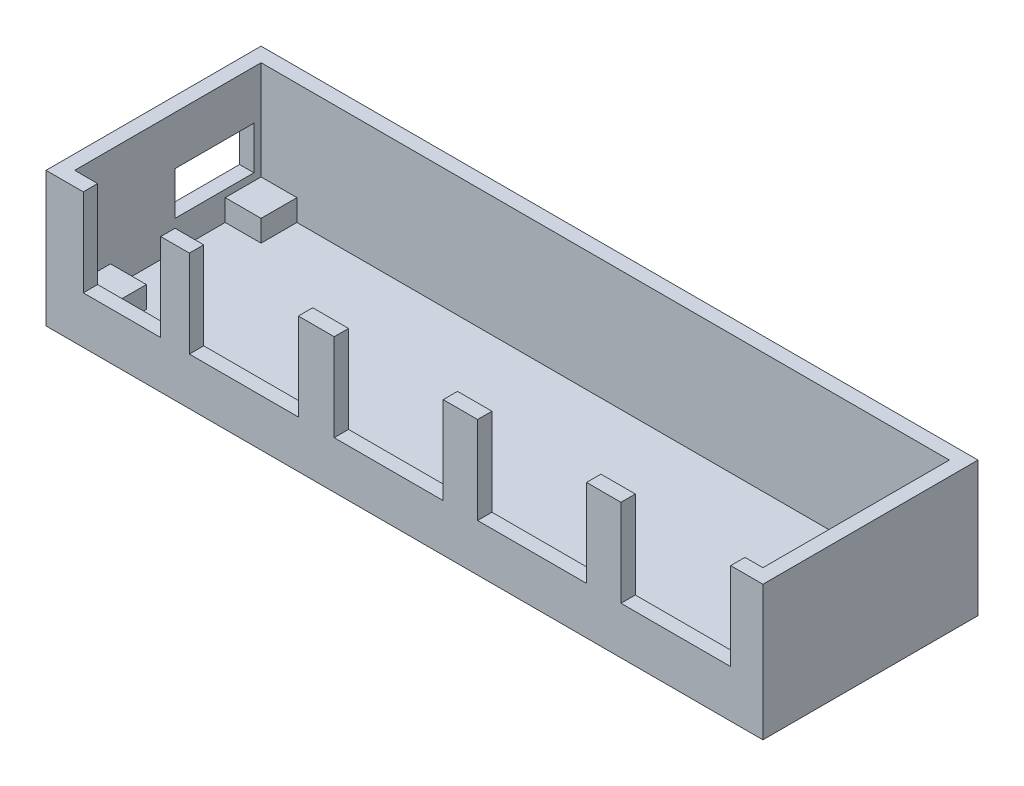
from build123d import *

# Parameters (mm, degrees)
BOSS_EXTRUDE1_DEPTH   = 16.8
SKETCH1_W             = 4.8
SKETCH1_H             = 2
BOSS_EXTRUDE1_2_DEPTH = 16.8
SKETCH1_W_2           = 4
BOSS_EXTRUDE1_3_DEPTH = 16.8
BOSS_EXTRUDE1_4_DEPTH = 16.8
SKETCH1_W_3           = 5
BOSS_EXTRUDE1_5_DEPTH = 16.8
SKETCH1_3_W           = 100
SKETCH1_3_H           = 30
BOSS_EXTRUDE2_DEPTH   = 2
SKETCH1_6_W           = 15.3
SKETCH1_6_H           = 2
SKETCH1_6_W_2         = 10.8
SKETCH1_6_W_3         = 15.2
BOSS_EXTRUDE4_DEPTH   = 4.6
SKETCH3_W             = 5
SKETCH3_H             = 5
BOSS_EXTRUDE5_DEPTH   = 3
SKETCH4_W             = 11
SKETCH4_H             = 6
CUT_EXTRUDE2_DEPTH    = 4


with BuildPart() as part:
    # Sketch1 → Boss-Extrude1 (new body)
    with BuildSketch(Plane(origin=(0, 0, 0), x_dir=(1, 0, 0), z_dir=(0, 1, 0))):
        Polygon((-87.471226233, -53.96631097), (-87.471226233, -27.96631097), (8.528773767, -27.96631097), (8.528773767, -53.96631097), (6.028773767, -53.96631097), (6.028773767, -55.96631097), (10.528773767, -55.96631097), (10.528773767, -25.96631097), (-89.471226233, -25.96631097), (-89.471226233, -55.96631097), (-84.271226233, -55.96631097), (-84.271226233, -53.96631097), align=None)
    extrude(amount=BOSS_EXTRUDE1_DEPTH)



with BuildPart() as body_2:
    # Sketch1 → Boss-Extrude1 2 (new body)
    with BuildSketch(Plane(origin=(0, 0, 0), x_dir=(1, 0, 0), z_dir=(0, 1, 0))):
        with Locations((-11.671226233, -54.96631097)):
            Rectangle(SKETCH1_W, SKETCH1_H)
    extrude(amount=BOSS_EXTRUDE1_2_DEPTH)


with BuildPart() as body_3:
    # Sketch1 → Boss-Extrude1 3 (new body)
    with BuildSketch(Plane(origin=(0, 0, 0), x_dir=(1, 0, 0), z_dir=(0, 1, 0))):
        with Locations((-71.471226233, -54.96631097)):
            Rectangle(SKETCH1_W_2, SKETCH1_H)
    extrude(amount=BOSS_EXTRUDE1_3_DEPTH)


with BuildPart() as body_4:
    # Sketch1 → Boss-Extrude1 4 (new body)
    with BuildSketch(Plane(origin=(0, 0, 0), x_dir=(1, 0, 0), z_dir=(0, 1, 0))):
        with Locations((-31.671226233, -54.96631097)):
            Rectangle(SKETCH1_W, SKETCH1_H)
    extrude(amount=BOSS_EXTRUDE1_4_DEPTH)


with BuildPart() as body_5:
    # Sketch1 → Boss-Extrude1 5 (new body)
    with BuildSketch(Plane(origin=(0, 0, 0), x_dir=(1, 0, 0), z_dir=(0, 1, 0))):
        with Locations((-51.771226233, -54.96631097)):
            Rectangle(SKETCH1_W_3, SKETCH1_H)
    extrude(amount=BOSS_EXTRUDE1_5_DEPTH)


with BuildPart() as part_1:
    add(part.part)

    add(body_2.part)  # Boss-Extrude2 merges body 2

    add(body_3.part)  # Boss-Extrude2 merges body 3

    add(body_4.part)  # Boss-Extrude2 merges body 4

    add(body_5.part)  # Boss-Extrude2 merges body 5
    # Sketch1_3 → Boss-Extrude2 (add)
    with BuildSketch(Plane(origin=(0, 0, 0), x_dir=(1, 0, 0), z_dir=(0, 1, 0))):
        with Locations((-39.471226233, -40.96631097)):
            Rectangle(SKETCH1_3_W, SKETCH1_3_H)
    extrude(amount=-BOSS_EXTRUDE2_DEPTH)

    # Sketch1_6 → Boss-Extrude4 (add)
    with BuildSketch(Plane(origin=(0, 0, 0), x_dir=(1, 0, 0), z_dir=(0, 1, 0))):
        with Locations((-1.621226233, -54.96631097)):
            Rectangle(SKETCH1_6_W, SKETCH1_6_H)
        with Locations((-78.871226233, -54.96631097)):
            Rectangle(SKETCH1_6_W_2, SKETCH1_6_H)
        with Locations((-21.671226233, -54.96631097)):
            Rectangle(SKETCH1_6_W_3, SKETCH1_6_H)
        with Locations((-61.871226233, -54.96631097)):
            Rectangle(SKETCH1_6_W_3, SKETCH1_6_H)
        with Locations((-41.671226233, -54.96631097)):
            Rectangle(SKETCH1_6_W_3, SKETCH1_6_H)
    extrude(amount=BOSS_EXTRUDE4_DEPTH)

    # Sketch3 → Boss-Extrude5 (add)
    with BuildSketch(Plane(origin=(0, 0, 0), x_dir=(1, 0, 0), z_dir=(0, 1, 0))):
        with Locations((-84.971226233, -30.46631097)):
            Rectangle(SKETCH3_W, SKETCH3_H)
        with Locations((6.028773767, -30.46631097)):
            Rectangle(SKETCH3_W, SKETCH3_H)
        with Locations((6.028773767, -51.46631097)):
            Rectangle(SKETCH3_W, SKETCH3_H)
        with Locations((-84.971226233, -51.46631097)):
            Rectangle(SKETCH3_W, SKETCH3_H)
    extrude(amount=BOSS_EXTRUDE5_DEPTH)

    # Sketch4 → Cut-Extrude2 (cut)
    with BuildSketch(Plane.ZY.offset(89.471226233)):
        with Locations((34.46631097, 7)):
            Rectangle(SKETCH4_W, SKETCH4_H)
    extrude(amount=-CUT_EXTRUDE2_DEPTH, mode=Mode.SUBTRACT)


solid = part_1.part
